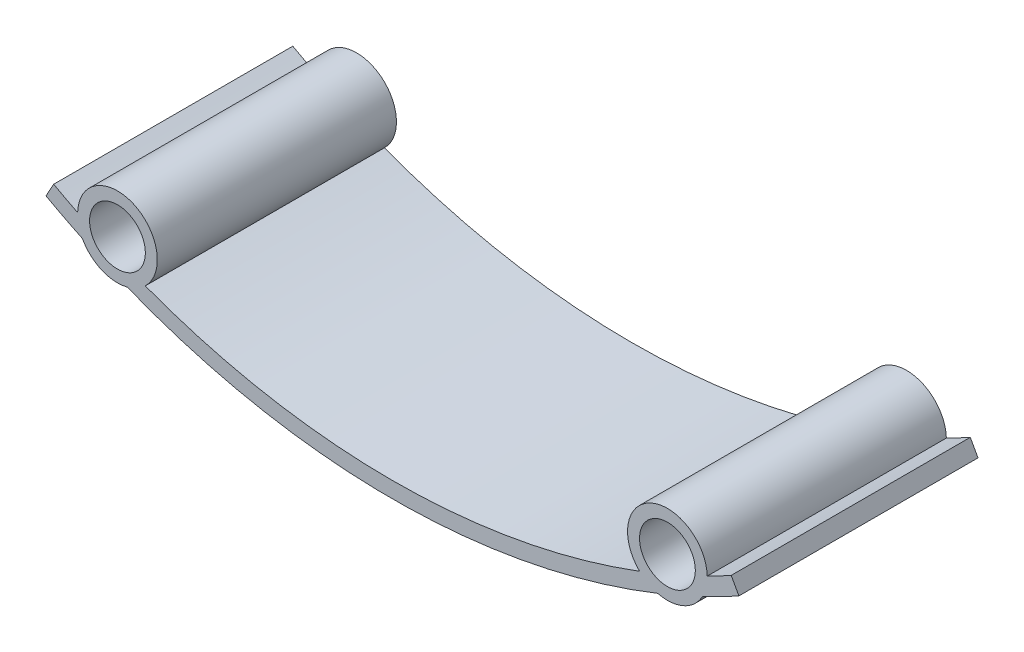
from build123d import *

# Parameters (mm, degrees)
SKETCH1_R           = 3.5
BOSS_EXTRUDE1_DEPTH = 30


with BuildPart() as part:
    # Sketch1 → Boss-Extrude1 (new body)
    with BuildSketch(Plane.XY):
        with BuildLine():
            ThreePointArc((33.272867256, 6.376341239), (36.505813953, 6.6433833), (38.894452917, 8.83830009))
            ThreePointArc((38.894452917, 8.83830009), (41.196992362, 9.982453047), (43.465909091, 11.19191192))
            Line((43.465909091, 11.19191192), (42.5, 12.943202766))
            ThreePointArc((42.5, 12.943202766), (41.006656684, 12.138237192), (39.498073317, 11.362208804))
            ThreePointArc((39.498073317, 11.362208804), (32.494186047, 15.80345107), (31.008619489, 7.644274532))
            ThreePointArc((31.008619489, 7.644274532), (0, 2), (-31.008619489, 7.644274532))
            ThreePointArc((-31.008619489, 7.644274532), (-32.494186047, 15.80345107), (-39.498073317, 11.362208804))
            ThreePointArc((-39.498073317, 11.362208804), (-41.006656684, 12.138237192), (-42.5, 12.943202766))
            Line((-42.5, 12.943202766), (-43.465909091, 11.19191192))
            ThreePointArc((-43.465909091, 11.19191192), (-41.196992362, 9.982453047), (-38.894452917, 8.83830009))
            ThreePointArc((-38.894452917, 8.83830009), (-36.505813953, 6.6433833), (-33.272867256, 6.376341239))
            ThreePointArc((-33.272867256, 6.376341239), (0, 0), (33.272867256, 6.376341239))
        make_face()
        with Locations((-34.5, 11.223417185)):
            Circle(SKETCH1_R, mode=Mode.SUBTRACT)
        with Locations((34.5, 11.223417185)):
            Circle(SKETCH1_R, mode=Mode.SUBTRACT)
    extrude(amount=BOSS_EXTRUDE1_DEPTH)


solid = part.part
